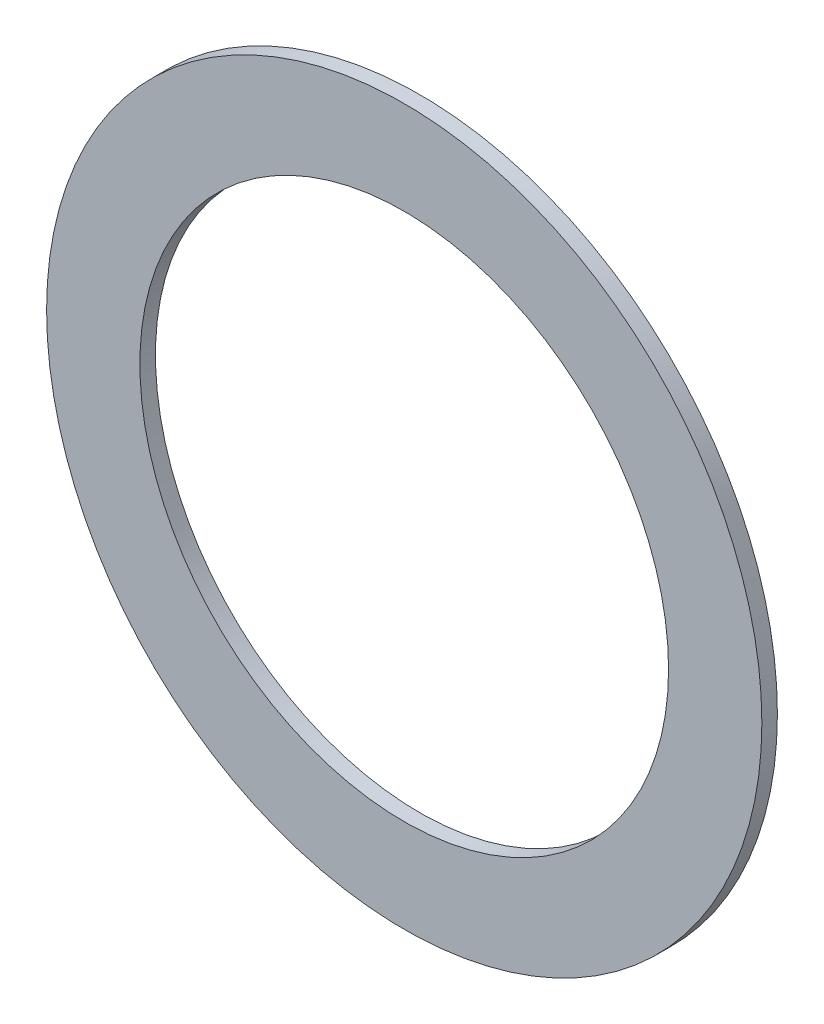
from build123d import *

# Parameters (mm, degrees)
SKICA1_R                = 46
SKICA1_R_2              = 34
P_IDAT_VYSUNUT_M1_DEPTH = 2


with BuildPart() as part:
    # Skica1 → Přidat vysunutím1 (new body)
    with BuildSketch(Plane.XY):
        Circle(SKICA1_R)
        Circle(SKICA1_R_2, mode=Mode.SUBTRACT)
    extrude(amount=P_IDAT_VYSUNUT_M1_DEPTH)


solid = part.part
